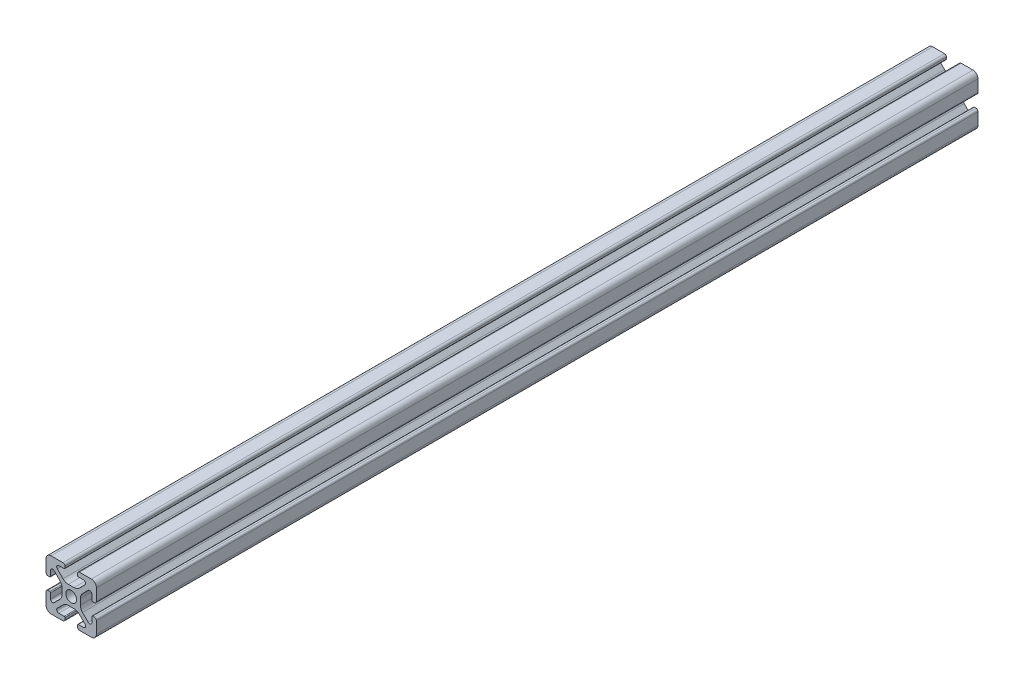
from build123d import *

# Parameters (mm, degrees)
SKETCH1_R           = 2.1463
BOSS_EXTRUDE1_DEPTH = 175


with BuildPart() as part:
    # Sketch1 → Boss-Extrude1 (new body, symmetric)
    with BuildSketch(Plane.XY):
        with BuildLine():
            Line((-9.9949, 7.9883), (-9.9949, 3.2893))
            ThreePointArc((-9.9949, 3.2893), (-9.76427588, 2.73252412), (-9.2075, 2.5019))
            Line((-9.2075, 2.5019), (-8.4963, 2.5019))
            ThreePointArc((-8.4963, 2.5019), (-8.280773853, 2.591173853), (-8.1915, 2.8067))
            Line((-8.1915, 2.8067), (-8.1915, 4.9149))
            ThreePointArc((-8.1915, 4.9149), (-7.674065253, 5.689295824), (-6.760603096, 5.507596904))
            Line((-6.760603096, 5.507596904), (-4.505765747, 3.252759555))
            ThreePointArc((-4.505765747, 3.252759555), (-3.856054457, 2.280397894), (-3.627906192, 1.133419111))
            Line((-3.627906192, 1.133419111), (-3.627906192, -1.133419111))
            ThreePointArc((-3.627906192, -1.133419111), (-3.856054457, -2.280397894), (-4.505765747, -3.252759555))
            Line((-4.505765747, -3.252759555), (-6.760603096, -5.507596904))
            ThreePointArc((-6.760603096, -5.507596904), (-7.674065253, -5.689295824), (-8.1915, -4.9149))
            Line((-8.1915, -4.9149), (-8.1915, -2.8067))
            ThreePointArc((-8.1915, -2.8067), (-8.280773853, -2.591173853), (-8.4963, -2.5019))
            Line((-8.4963, -2.5019), (-9.2075, -2.5019))
            ThreePointArc((-9.2075, -2.5019), (-9.76427588, -2.73252412), (-9.9949, -3.2893))
            Line((-9.9949, -3.2893), (-9.9949, -7.9883))
            ThreePointArc((-9.9949, -7.9883), (-9.407180467, -9.407180467), (-7.9883, -9.9949))
            Line((-7.9883, -9.9949), (-3.2893, -9.9949))
            ThreePointArc((-3.2893, -9.9949), (-2.73252412, -9.76427588), (-2.5019, -9.2075))
            Line((-2.5019, -9.2075), (-2.5019, -8.4963))
            ThreePointArc((-2.5019, -8.4963), (-2.591173853, -8.280773853), (-2.8067, -8.1915))
            Line((-2.8067, -8.1915), (-4.9149, -8.1915))
            ThreePointArc((-4.9149, -8.1915), (-5.689295824, -7.674065253), (-5.507596904, -6.760603096))
            Line((-5.507596904, -6.760603096), (-3.252759555, -4.505765747))
            ThreePointArc((-3.252759555, -4.505765747), (-2.280397894, -3.856054457), (-1.133419111, -3.627906192))
            Line((-1.133419111, -3.627906192), (1.133419111, -3.627906192))
            ThreePointArc((1.133419111, -3.627906192), (2.280397894, -3.856054457), (3.252759555, -4.505765747))
            Line((3.252759555, -4.505765747), (5.507596904, -6.760603096))
            ThreePointArc((5.507596904, -6.760603096), (5.689295824, -7.674065253), (4.9149, -8.1915))
            Line((4.9149, -8.1915), (2.8067, -8.1915))
            ThreePointArc((2.8067, -8.1915), (2.591173853, -8.280773853), (2.5019, -8.4963))
            Line((2.5019, -8.4963), (2.5019, -9.2075))
            ThreePointArc((2.5019, -9.2075), (2.73252412, -9.76427588), (3.2893, -9.9949))
            Line((3.2893, -9.9949), (7.9883, -9.9949))
            ThreePointArc((7.9883, -9.9949), (9.407180467, -9.407180467), (9.9949, -7.9883))
            Line((9.9949, -7.9883), (9.9949, -3.2893))
            ThreePointArc((9.9949, -3.2893), (9.76427588, -2.73252412), (9.2075, -2.5019))
            Line((9.2075, -2.5019), (8.4963, -2.5019))
            ThreePointArc((8.4963, -2.5019), (8.280773853, -2.591173853), (8.1915, -2.8067))
            Line((8.1915, -2.8067), (8.1915, -4.9149))
            ThreePointArc((8.1915, -4.9149), (7.674065253, -5.689295824), (6.760603096, -5.507596904))
            Line((6.760603096, -5.507596904), (4.505765747, -3.252759555))
            ThreePointArc((4.505765747, -3.252759555), (3.856054457, -2.280397894), (3.627906192, -1.133419111))
            Line((3.627906192, -1.133419111), (3.627906192, 1.133419111))
            ThreePointArc((3.627906192, 1.133419111), (3.856054457, 2.280397894), (4.505765747, 3.252759555))
            Line((4.505765747, 3.252759555), (6.760603096, 5.507596904))
            ThreePointArc((6.760603096, 5.507596904), (7.674065253, 5.689295824), (8.1915, 4.9149))
            Line((8.1915, 4.9149), (8.1915, 2.8067))
            ThreePointArc((8.1915, 2.8067), (8.280773853, 2.591173853), (8.4963, 2.5019))
            Line((8.4963, 2.5019), (9.2075, 2.5019))
            ThreePointArc((9.2075, 2.5019), (9.76427588, 2.73252412), (9.9949, 3.2893))
            Line((9.9949, 3.2893), (9.9949, 7.9883))
            ThreePointArc((9.9949, 7.9883), (9.407180467, 9.407180467), (7.9883, 9.9949))
            Line((7.9883, 9.9949), (3.2893, 9.9949))
            ThreePointArc((3.2893, 9.9949), (2.73252412, 9.76427588), (2.5019, 9.2075))
            Line((2.5019, 9.2075), (2.5019, 8.4963))
            ThreePointArc((2.5019, 8.4963), (2.591173853, 8.280773853), (2.8067, 8.1915))
            Line((2.8067, 8.1915), (4.9149, 8.1915))
            ThreePointArc((4.9149, 8.1915), (5.689295824, 7.674065253), (5.507596904, 6.760603096))
            Line((5.507596904, 6.760603096), (3.252759555, 4.505765747))
            ThreePointArc((3.252759555, 4.505765747), (2.280397894, 3.856054457), (1.133419111, 3.627906192))
            Line((1.133419111, 3.627906192), (-1.133419111, 3.627906192))
            ThreePointArc((-1.133419111, 3.627906192), (-2.280397894, 3.856054457), (-3.252759555, 4.505765747))
            Line((-3.252759555, 4.505765747), (-5.507596904, 6.760603096))
            ThreePointArc((-5.507596904, 6.760603096), (-5.689295824, 7.674065253), (-4.9149, 8.1915))
            Line((-4.9149, 8.1915), (-2.8067, 8.1915))
            ThreePointArc((-2.8067, 8.1915), (-2.591173853, 8.280773853), (-2.5019, 8.4963))
            Line((-2.5019, 8.4963), (-2.5019, 9.2075))
            ThreePointArc((-2.5019, 9.2075), (-2.73252412, 9.76427588), (-3.2893, 9.9949))
            Line((-3.2893, 9.9949), (-7.9883, 9.9949))
            ThreePointArc((-7.9883, 9.9949), (-9.407180467, 9.407180467), (-9.9949, 7.9883))
        make_face()
        Circle(SKETCH1_R, mode=Mode.SUBTRACT)
    extrude(amount=BOSS_EXTRUDE1_DEPTH, both=True)


solid = part.part
